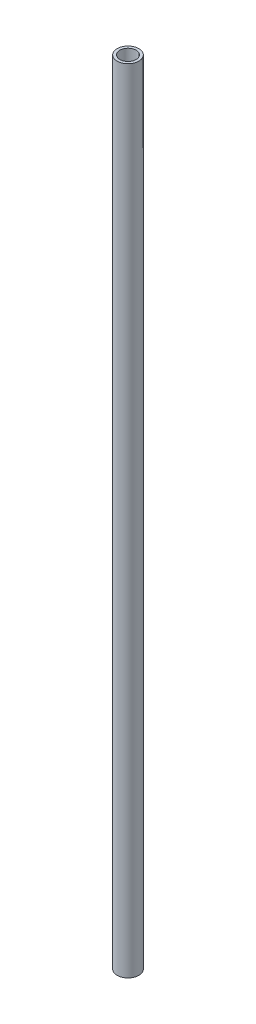
from build123d import *

# Parameters (mm, degrees)
SKETCH1_R           = 12.7
SKETCH1_R_2         = 9.525
BOSS_EXTRUDE1_DEPTH = 463.55


with BuildPart() as part:
    # Sketch1 → Boss-Extrude1 (new body, symmetric)
    with BuildSketch(Plane(origin=(0, 0, 0), x_dir=(1, 0, 0), z_dir=(0, 1, 0))):
        Circle(SKETCH1_R)
        Circle(SKETCH1_R_2, mode=Mode.SUBTRACT)
    extrude(amount=BOSS_EXTRUDE1_DEPTH, both=True)


solid = part.part
